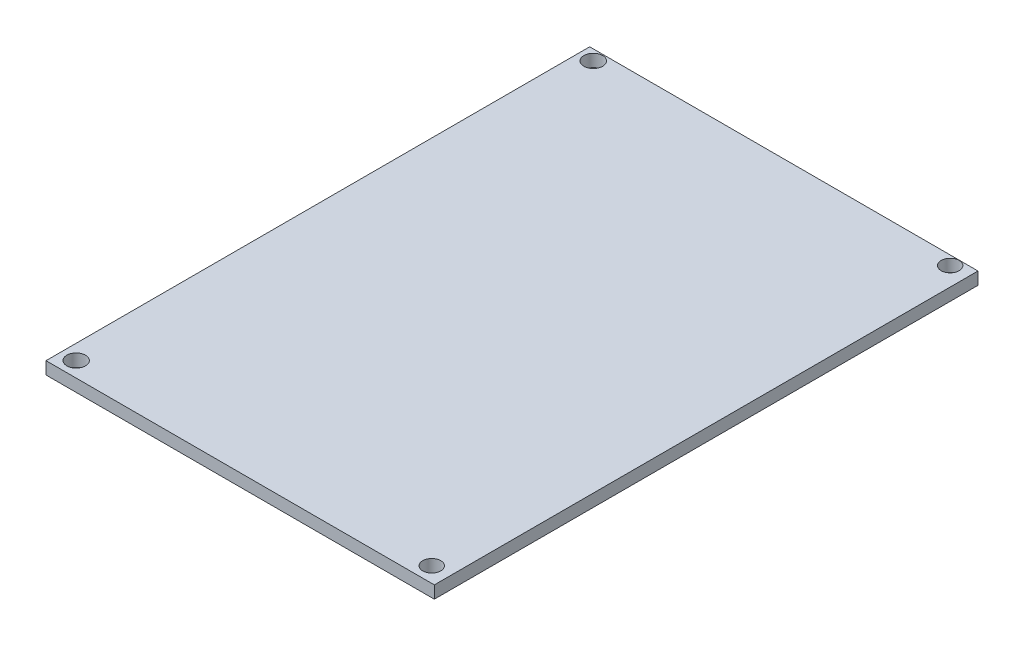
from build123d import *

# Parameters (mm, degrees)
SKETCH1_W           = 50
SKETCH1_H           = 70
BOSS_EXTRUDE1_DEPTH = 1.6
SKETCH2_R           = 1.206691902
SKETCH2_R_2         = 1.154285223
SKETCH2_R_3         = 1.1548972
SKETCH2_R_4         = 1.200373214
CUT_EXTRUDE1_DEPTH  = 10


with BuildPart() as part:
    # Sketch1 → Boss-Extrude1 (new body)
    with BuildSketch(Plane(origin=(0, 0, 0), x_dir=(1, 0, 0), z_dir=(0, 1, 0))):
        with Locations((-5, -14.824561404)):
            Rectangle(SKETCH1_W, SKETCH1_H)
    extrude(amount=BOSS_EXTRUDE1_DEPTH)

    # Sketch2 → Cut-Extrude1 (cut)
    with BuildSketch(Plane(origin=(0, 1.6, 0), x_dir=(1, 0, 0), z_dir=(0, 1, 0))):
        with Locations((-28.190504792, 18.832573543)):
            Circle(SKETCH2_R)
        with Locations((17.604318255, 18.987717923)):
            Circle(SKETCH2_R_2)
        with Locations((17.705615947, -47.864216218)):
            Circle(SKETCH2_R_3)
        with Locations((-28.074153704, -47.864216218)):
            Circle(SKETCH2_R_4)
    extrude(amount=-CUT_EXTRUDE1_DEPTH, mode=Mode.SUBTRACT)


solid = part.part
